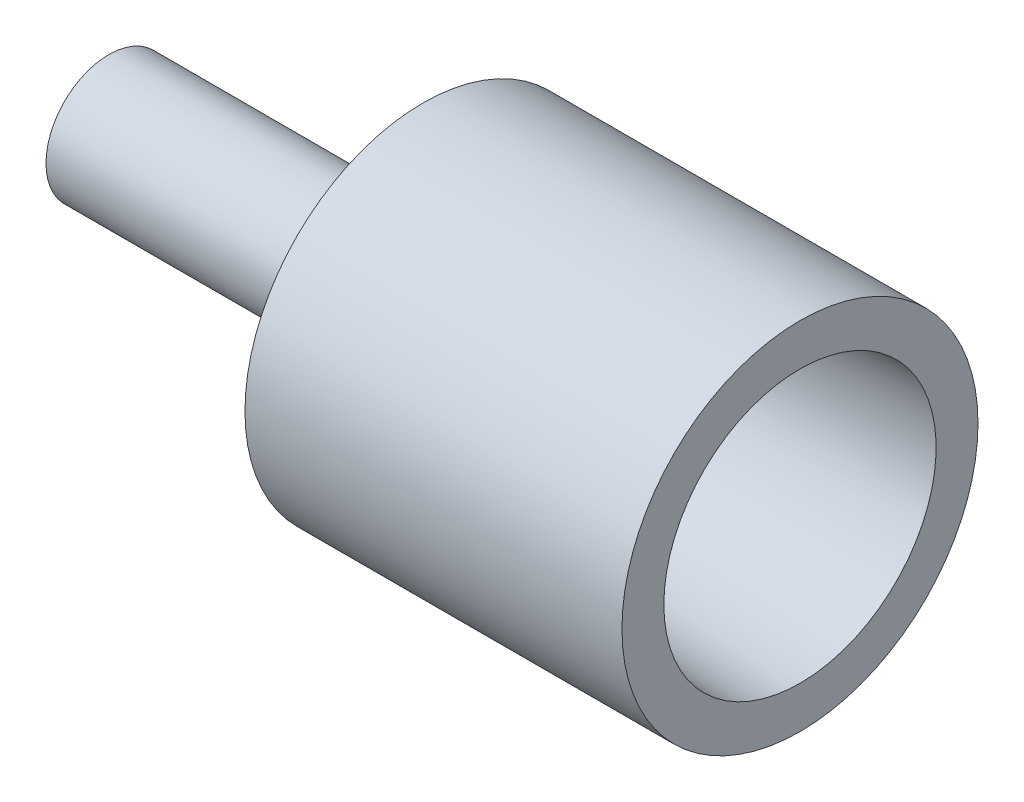
from build123d import *

# Parameters (mm, degrees)
CHAMFER_1_SIZE = 3


with BuildPart() as part:
    # 草图1 → 旋转1 (revolve)
    with BuildSketch(Plane(origin=(0, 0, 0), x_dir=(1, 0, 0), z_dir=(0, 1, 0))):
        Polygon((15, 8.5), (-3, 8.5), (-3, 3), (-18, 3), (-18, 0), (0, 0), (0, 5.75), (15, 6.5), align=None)
    revolve(axis=Axis((-18, 0, 0), (1, 0, 0)))

    # 倒角1
    chamfer_1_edges = [part.edges().sort_by_distance(p)[0] for p in [
        (-3, 0, 3),
    ]]
    chamfer(chamfer_1_edges, length=CHAMFER_1_SIZE)


solid = part.part
